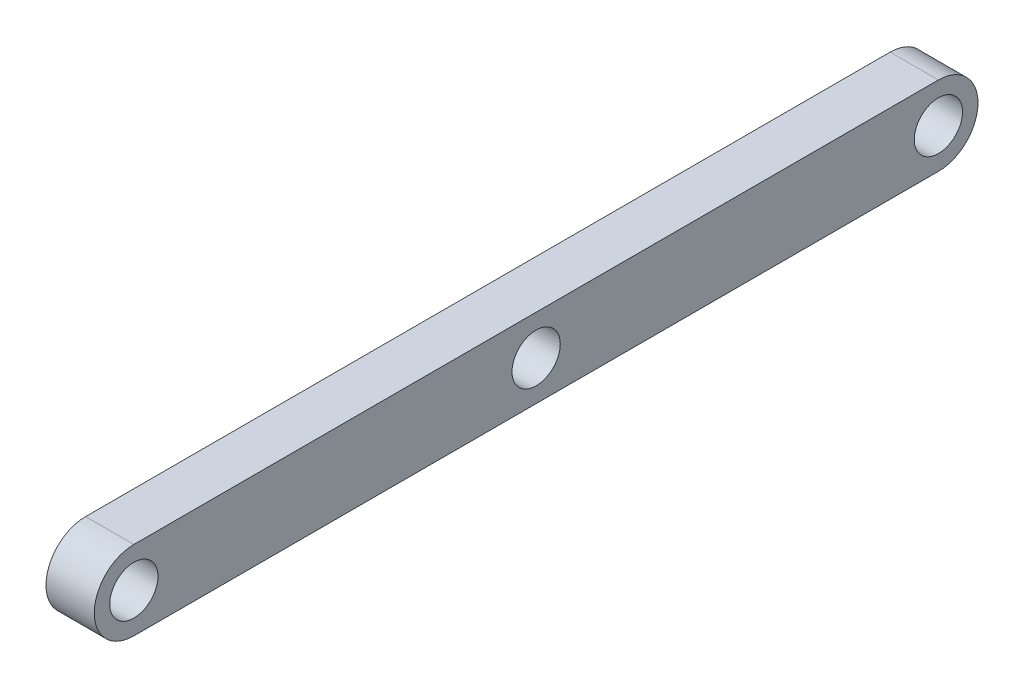
from build123d import *

# Parameters (mm, degrees)
SKETCH1_R           = 15
BOSS_EXTRUDE1_DEPTH = 30


with BuildPart() as part:
    # Sketch1 → Boss-Extrude1 (new body)
    with BuildSketch(Plane(origin=(0, 0, 0), x_dir=(0, 0, -1), z_dir=(1, 0, 0))):
        with BuildLine():
            Line((-48.878566689, 24.607830126), (451.121433311, 24.607830126))
            ThreePointArc((451.121433311, 24.607830126), (475.729263437, 0), (451.121433311, -24.607830126))
            Line((451.121433311, -24.607830126), (-48.878566689, -24.607830126))
            ThreePointArc((-48.878566689, -24.607830126), (-73.486396815, 0), (-48.878566689, 24.607830126))
        make_face()
        with Locations((-48.878566689, 0)):
            Circle(SKETCH1_R, mode=Mode.SUBTRACT)
        with Locations((451.121433311, 0)):
            Circle(SKETCH1_R, mode=Mode.SUBTRACT)
        with Locations((201.121433311, 0)):
            Circle(SKETCH1_R, mode=Mode.SUBTRACT)
    extrude(amount=BOSS_EXTRUDE1_DEPTH)


solid = part.part
